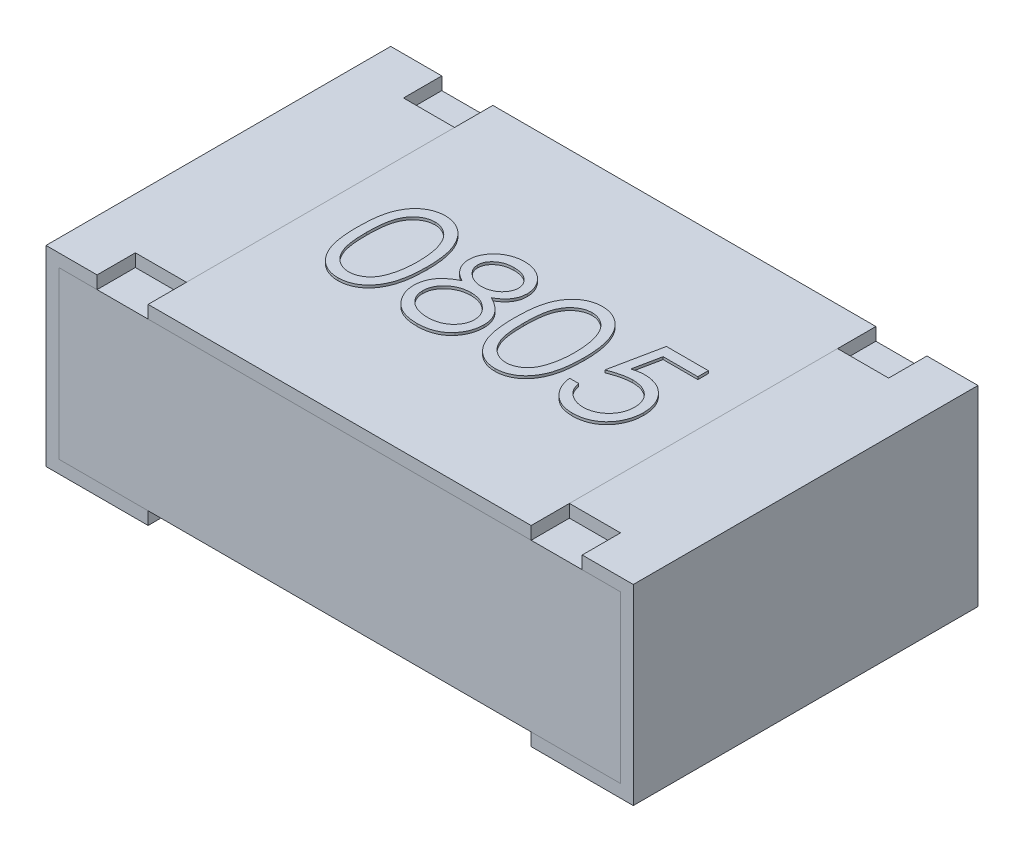
from build123d import *

# Parameters (mm, degrees)
CROQUIS1_W          = 2.2
CROQUIS1_H          = 1.35
EXTRUIR1_DEPTH      = 0.7
CROQUIS2_W          = 2.2
CROQUIS2_H          = 0.05
EXTRUIR2_DEPTH      = 2.876832438
CROQUIS4_W          = 1.35
CROQUIS4_H          = 0.05
EXTRUIR3_DEPTH      = 1.5
CROQUIS5_W          = 0.2
CROQUIS5_H          = 0.15
EXTRUIR4_DEPTH      = 0.05
BOSS_EXTRUDE1_DEPTH = 0.01


with BuildPart() as part:
    # Croquis1 → Extruir1 (new body)
    with BuildSketch(Plane(origin=(0, 0, 0), x_dir=(1, 0, 0), z_dir=(0, 1, 0))):
        Rectangle(CROQUIS1_W, CROQUIS1_H)
    extrude(amount=EXTRUIR1_DEPTH)

    # Croquis2 → Extruir2 (cut, through all)
    with BuildSketch(Plane.XY.offset(0.675)):
        with Locations((0, 0.025)):
            Rectangle(CROQUIS2_W, CROQUIS2_H)
    extrude(amount=-EXTRUIR2_DEPTH, mode=Mode.SUBTRACT)


with BuildPart() as body_2:
    # Barrer1: sweep along a path in Croquis3
    with BuildLine(Plane.XY.offset(0.675)) as barrer1_path:
        Line((-0.75, 0.75), (-1.15, 0.75))
        Line((-1.15, 0.75), (-1.15, 0))
        Line((-1.15, 0), (-0.75, 0))
    # Croquis3D1 → Barrer1 (sweep)
    with BuildSketch(Plane(origin=(-0.75, 0.75, 0.675), x_dir=(0, -0.0370116605098802, -0.9993148337667672), z_dir=(-1, 0, 0))):
        Polygon((0, 0), (1.349075026, -0.049965742), (1.350925609, 0), (0.001850583, 0.049965742), align=None)
    sweep(path=barrer1_path.line, transition=Transition.RIGHT)


with BuildPart() as body_3:
    # Simetría1: mirrored copy
    add(body_2.part.mirror(Plane(origin=(0, 0.7, 0.675), x_dir=(0, 0, 1), z_dir=(1, 0, 0))))


with BuildPart() as body_4:
    # Croquis4 → Extruir3 (new body)
    with BuildSketch(Plane(origin=(-0.75, 0, 0), x_dir=(0, 0, -1), z_dir=(1, 0, 0))):
        with Locations((0, 0.725)):
            Rectangle(CROQUIS4_W, CROQUIS4_H)
    extrude(amount=EXTRUIR3_DEPTH)

    # Sketch1 → Boss-Extrude1 (add)
    with BuildSketch(Plane(origin=(0, 0.75, 0), x_dir=(1, 0, 0), z_dir=(0, 1, 0))):
        with BuildLine():
            add(Edge.make_bspline(
                [(-0.59261561, -0.012986983), (-0.592578122, -0.006575853), (-0.592505301, 0.005877859), (-0.591695196, 0.024024675), (-0.590349443, 0.041048708), (-0.588505172, 0.056950773), (-0.586260831, 0.071734975), (-0.583264775, 0.085361804), (-0.579857598, 0.097894331), (-0.575908747, 0.109373422), (-0.571453, 0.119953731), (-0.56660337, 0.129830897), (-0.561167393, 0.138989975), (-0.555455746, 0.147577151), (-0.549237224, 0.155451859), (-0.542688791, 0.162725306), (-0.535554862, 0.169229392), (-0.528077947, 0.175154683), (-0.520190351, 0.180348909), (-0.512116903, 0.184924079), (-0.503802034, 0.188832635), (-0.495223042, 0.191905828), (-0.486457035, 0.19444421), (-0.47747337, 0.19618009), (-0.468257214, 0.197272308), (-0.462036479, 0.197376727), (-0.458881635, 0.197429683)],
                knots=[0, 0, 0, 0, 1.646270934, 3.197905019, 4.663502075, 6.030701355, 7.308322542, 8.50163776, 9.611534131, 10.641858119, 11.616356847, 12.558055219, 13.465016945, 14.349605745, 15.204443733, 16.039544428, 16.859896111, 17.680448484, 18.487036065, 19.28249412, 20.06191084, 20.843045899, 21.620316918, 22.403196591, 23.190181807, 24, 24, 24, 24], degree=3))
            add(Edge.make_bspline(
                [(-0.458881635, 0.197429683), (-0.455700438, 0.197373933), (-0.449374037, 0.197263063), (-0.440020851, 0.19619747), (-0.430883745, 0.194429341), (-0.422001672, 0.191924087), (-0.413301673, 0.18881601), (-0.404851798, 0.184920339), (-0.39659956, 0.180385612), (-0.388676099, 0.175057168), (-0.380994428, 0.169116337), (-0.373743233, 0.162400603), (-0.366921851, 0.154977778), (-0.360444674, 0.146927279), (-0.354495463, 0.138094698), (-0.348829927, 0.128633657), (-0.343758838, 0.118378701), (-0.338874875, 0.107500934), (-0.334659219, 0.095699372), (-0.330857363, 0.083040543), (-0.32778548, 0.069374921), (-0.325226706, 0.054774208), (-0.323244433, 0.039184781), (-0.321800702, 0.022640059), (-0.321038064, 0.005129157), (-0.320894441, -0.006843168), (-0.320820738, -0.012986983)],
                knots=[0, 0, 0, 0, 0.810914788, 1.612654377, 2.396697861, 3.181598691, 3.963628158, 4.749916497, 5.551656086, 6.361998678, 7.18212741, 8.025565596, 8.878627764, 9.750805457, 10.657531673, 11.591944965, 12.560506719, 13.57287815, 14.630710178, 15.753379473, 16.941251878, 18.199788006, 19.531962791, 20.947069417, 22.433333509, 24, 24, 24, 24], degree=3))
            add(Edge.make_bspline(
                [(-0.320820738, -0.012986983), (-0.320895205, -0.019104001), (-0.3210403, -0.031022762), (-0.321792153, -0.048454873), (-0.323273139, -0.064911792), (-0.325125709, -0.080432988), (-0.327691533, -0.094953859), (-0.33084641, -0.108524653), (-0.334349304, -0.121203975), (-0.33867328, -0.132887954), (-0.343405933, -0.143739579), (-0.348555098, -0.153872968), (-0.35407165, -0.163377687), (-0.360081792, -0.172177658), (-0.366487896, -0.180335219), (-0.373427072, -0.187706376), (-0.38070371, -0.194468738), (-0.388407986, -0.200486067), (-0.396455021, -0.205752902), (-0.404678915, -0.210463056), (-0.413225588, -0.214261078), (-0.421901354, -0.217522226), (-0.43083031, -0.220013706), (-0.440001326, -0.221736433), (-0.449367753, -0.222944644), (-0.45569936, -0.223036813), (-0.458881635, -0.223083137)],
                knots=[0, 0, 0, 0, 1.561518951, 3.042555995, 4.452378317, 5.7783523, 7.031515105, 8.214008947, 9.334062868, 10.386615937, 11.391082383, 12.354592575, 13.286541444, 14.194233754, 15.072674879, 15.931287219, 16.775624067, 17.606195743, 18.42308326, 19.229000347, 20.022332153, 20.807536673, 21.593273796, 22.3848459, 23.188221202, 24, 24, 24, 24], degree=3))
            add(Edge.make_bspline(
                [(-0.458881635, -0.223083137), (-0.462036391, -0.22302984), (-0.468256954, -0.222924747), (-0.477474374, -0.221837463), (-0.486420939, -0.220089406), (-0.495140797, -0.217641794), (-0.503678684, -0.214645812), (-0.51191826, -0.210742534), (-0.519951138, -0.206247212), (-0.527755887, -0.201127735), (-0.535185849, -0.1952624), (-0.542282832, -0.188775053), (-0.548868548, -0.181503806), (-0.554998159, -0.173563472), (-0.560823769, -0.165027101), (-0.566182555, -0.155778144), (-0.571139224, -0.145853275), (-0.575669909, -0.135188371), (-0.579686899, -0.123627807), (-0.583235208, -0.11103933), (-0.586036826, -0.097311829), (-0.588434878, -0.082555558), (-0.590369094, -0.066707109), (-0.591689588, -0.049757877), (-0.592505738, -0.031718425), (-0.592578318, -0.019344736), (-0.59261561, -0.012986983)],
                knots=[0, 0, 0, 0, 0.810891512, 1.598919785, 2.382837074, 3.152667961, 3.926044502, 4.706494248, 5.493654104, 6.291793342, 7.103789334, 7.925228297, 8.761435821, 9.622817696, 10.50288917, 11.416980706, 12.369136599, 13.353924996, 14.394355917, 15.514179734, 16.714354668, 17.994756427, 19.357759367, 20.818452758, 22.365282078, 24, 24, 24, 24], degree=3))
        make_face()
        with BuildLine():
            add(Edge.make_bspline(
                [(-0.556718174, -0.012826727), (-0.556704523, -0.018169435), (-0.556678029, -0.028538583), (-0.555985892, -0.043606385), (-0.555043008, -0.057660137), (-0.55382686, -0.070717684), (-0.552020808, -0.082734828), (-0.549997175, -0.09379422), (-0.547534537, -0.103837333), (-0.54462082, -0.112933083), (-0.541302066, -0.121235834), (-0.537678539, -0.128961687), (-0.533785885, -0.136201908), (-0.529429411, -0.142891463), (-0.524684832, -0.149052168), (-0.519659317, -0.154793063), (-0.514165307, -0.159912718), (-0.506564879, -0.16605293), (-0.496530997, -0.172397974), (-0.483888659, -0.177923241), (-0.470897979, -0.181395522), (-0.462080693, -0.181837094), (-0.457679712, -0.182057496)],
                knots=[0, 0, 0, 0, 1.459021318, 2.831673884, 4.118529203, 5.306027144, 6.411944654, 7.436330062, 8.375795394, 9.233974572, 10.042671642, 10.816086306, 11.563610507, 12.285937304, 12.993564865, 13.685989202, 14.367179055, 15.041617293, 16.353048772, 17.594441528, 18.799311195, 20, 20, 20, 20], degree=3))
            add(Edge.make_bspline(
                [(-0.457679712, -0.182057496), (-0.453250264, -0.181874893), (-0.444400513, -0.181510063), (-0.431470936, -0.177990207), (-0.418918906, -0.172679402), (-0.409082112, -0.166399688), (-0.401598393, -0.160419307), (-0.396236451, -0.15532049), (-0.391315074, -0.149611248), (-0.386647409, -0.143451329), (-0.382366371, -0.136723045), (-0.378473441, -0.12945875), (-0.374921059, -0.121638273), (-0.372897168, -0.116178874), (-0.371862405, -0.113387624)],
                knots=[0, 0, 0, 0, 1.353760809, 2.704726607, 4.075137775, 5.516104923, 6.260822281, 7.007110065, 7.778089737, 8.566572457, 9.372053459, 10.217411131, 11.088608312, 12, 12, 12, 12], degree=3))
            add(Edge.make_bspline(
                [(-0.371862405, -0.113387624), (-0.370656488, -0.109818511), (-0.368207961, -0.102571681), (-0.36505233, -0.091330121), (-0.362567141, -0.079535519), (-0.360331328, -0.067258363), (-0.358805265, -0.054408112), (-0.357576943, -0.041024525), (-0.356853436, -0.027097512), (-0.35676375, -0.017635227), (-0.356718174, -0.012826727)],
                knots=[0, 0, 0, 0, 0.884706709, 1.796334032, 2.740027952, 3.714592787, 4.726048262, 5.777819803, 6.87074269, 8, 8, 8, 8], degree=3))
            add(Edge.make_bspline(
                [(-0.356718174, -0.012826727), (-0.356781053, -0.008019004), (-0.356904057, 0.001385929), (-0.357374227, 0.015159435), (-0.35858835, 0.028241465), (-0.359936821, 0.040688376), (-0.361925074, 0.052431268), (-0.364068824, 0.063568445), (-0.366948962, 0.073961934), (-0.370025508, 0.083774458), (-0.373546696, 0.092894532), (-0.37742278, 0.101364679), (-0.38156241, 0.109225791), (-0.386058666, 0.116456298), (-0.390858172, 0.123088589), (-0.396087606, 0.128989686), (-0.401539535, 0.134342482), (-0.409175785, 0.14045249), (-0.419172846, 0.146682398), (-0.431612349, 0.152415628), (-0.444557565, 0.155708004), (-0.453308817, 0.156172197), (-0.457679712, 0.156404042)],
                knots=[0, 0, 0, 0, 1.31362396, 2.569729283, 3.763502607, 4.902122613, 5.988968491, 7.01645872, 7.998833611, 8.933434873, 9.825090667, 10.667526885, 11.477055099, 12.250526234, 12.991942729, 13.710640831, 14.402115721, 15.076753259, 16.378508321, 17.609869233, 18.806226677, 20, 20, 20, 20], degree=3))
            add(Edge.make_bspline(
                [(-0.457679712, 0.156404042), (-0.46210378, 0.156171877), (-0.470959975, 0.155707123), (-0.484039741, 0.152427894), (-0.496577381, 0.146712127), (-0.506548007, 0.140431856), (-0.514189583, 0.134450334), (-0.519570462, 0.129263311), (-0.524615739, 0.123589453), (-0.529263476, 0.117372092), (-0.533616537, 0.110690335), (-0.537614367, 0.103491619), (-0.541216347, 0.095739463), (-0.544540294, 0.087440442), (-0.547462899, 0.078345477), (-0.549873637, 0.068314735), (-0.552100729, 0.057290519), (-0.553677331, 0.045208289), (-0.555078903, 0.032147472), (-0.555979629, 0.018058636), (-0.556680344, 0.002965563), (-0.556705311, -0.007457197), (-0.556718174, -0.012826727)],
                knots=[0, 0, 0, 0, 1.207732386, 2.417664972, 3.655092373, 4.956220595, 5.625982001, 6.301752483, 6.994047911, 7.697131622, 8.419323945, 9.170223765, 9.943494443, 10.752040957, 11.610060368, 12.549350801, 13.567764191, 14.679664412, 15.874934091, 17.154273443, 18.533957287, 20, 20, 20, 20], degree=3))
        make_face(mode=Mode.SUBTRACT)
        with BuildLine():
            add(Edge.make_bspline(
                [(-0.090452148, 0.010009811), (-0.087178029, 0.008302616), (-0.080792402, 0.004973016), (-0.071697864, -0.000388221), (-0.063386435, -0.006038617), (-0.055627514, -0.011711287), (-0.048557416, -0.017623476), (-0.042255198, -0.023798694), (-0.036565184, -0.030082802), (-0.031602123, -0.036582212), (-0.02723677, -0.043279657), (-0.023463955, -0.050192717), (-0.020239132, -0.057306241), (-0.017683367, -0.064697879), (-0.01557802, -0.072259052), (-0.014129379, -0.080087392), (-0.013350303, -0.088131317), (-0.01320301, -0.093567694), (-0.01312843, -0.096320317)],
                knots=[0, 0, 0, 0, 1.272397273, 2.481599622, 3.635517121, 4.734568067, 5.792894095, 6.808321871, 7.773003508, 8.711915296, 9.623354172, 10.525449501, 11.423591555, 12.311487226, 13.218079475, 14.126165749, 15.051214107, 16, 16, 16, 16], degree=3))
            add(Edge.make_bspline(
                [(-0.01312843, -0.096320317), (-0.013216593, -0.100171486), (-0.013391099, -0.107794396), (-0.014911097, -0.11904538), (-0.017186866, -0.129972441), (-0.020510239, -0.140573182), (-0.024820341, -0.150789111), (-0.030131979, -0.160628971), (-0.036144688, -0.170254034), (-0.040973516, -0.176176252), (-0.043416892, -0.179172881)],
                knots=[0, 0, 0, 0, 1.025265484, 2.029385089, 3.018602448, 3.995076438, 4.983346944, 5.966715145, 6.97116228, 8, 8, 8, 8], degree=3))
            add(Edge.make_bspline(
                [(-0.043416892, -0.179172881), (-0.046598203, -0.182669312), (-0.052921514, -0.189618969), (-0.063753848, -0.198641918), (-0.075642063, -0.206224706), (-0.088540159, -0.212404351), (-0.102413656, -0.217214164), (-0.117259599, -0.220670451), (-0.133106931, -0.222650158), (-0.143998985, -0.222936328), (-0.149586764, -0.223083137)],
                knots=[0, 0, 0, 0, 0.954267603, 1.896743057, 2.838368354, 3.796610408, 4.779680527, 5.799409237, 6.871065594, 8, 8, 8, 8], degree=3))
            add(Edge.make_bspline(
                [(-0.149586764, -0.223083137), (-0.154959722, -0.222951426), (-0.165414954, -0.222695128), (-0.180632997, -0.220958621), (-0.194818491, -0.217915437), (-0.208053916, -0.213750338), (-0.220259481, -0.208332027), (-0.231400407, -0.201588208), (-0.241637432, -0.193790329), (-0.250659886, -0.184714435), (-0.258669994, -0.174993535), (-0.265706343, -0.16496478), (-0.271554809, -0.154627253), (-0.276506477, -0.144135097), (-0.280297108, -0.133341251), (-0.282922504, -0.122301249), (-0.284589854, -0.111034376), (-0.284811698, -0.103430758), (-0.284923302, -0.099605573)],
                knots=[0, 0, 0, 0, 1.256902934, 2.445805442, 3.576955095, 4.645999104, 5.686449165, 6.692658513, 7.68621702, 8.689161843, 9.678783111, 10.630372946, 11.551080876, 12.453998257, 13.34127905, 14.221779781, 15.105423033, 16, 16, 16, 16], degree=3))
            add(Edge.make_bspline(
                [(-0.284923302, -0.099605573), (-0.284857259, -0.096798808), (-0.284726733, -0.09125165), (-0.283823322, -0.083056299), (-0.282370926, -0.075079598), (-0.280398417, -0.067292084), (-0.277725157, -0.059750453), (-0.274497485, -0.05241897), (-0.270733833, -0.045289359), (-0.2663817, -0.03832263), (-0.261318611, -0.0316164), (-0.255585623, -0.025056857), (-0.249068152, -0.018745787), (-0.241838705, -0.012606081), (-0.233979901, -0.006528827), (-0.225287612, -0.000842458), (-0.215992267, 0.004855595), (-0.209385935, 0.008262261), (-0.20599702, 0.010009811)],
                knots=[0, 0, 0, 0, 0.941657376, 1.861047343, 2.762797495, 3.66048619, 4.553285746, 5.444104102, 6.34607688, 7.256116206, 8.197091036, 9.162375105, 10.176350973, 11.237807142, 12.343728897, 13.50695164, 14.721116704, 16, 16, 16, 16], degree=3))
            add(Edge.make_bspline(
                [(-0.20599702, 0.010009811), (-0.210636034, 0.012539499), (-0.219618464, 0.017437683), (-0.231512115, 0.026437318), (-0.241728186, 0.036184497), (-0.249985868, 0.046885045), (-0.256485551, 0.058204688), (-0.26094482, 0.070072602), (-0.263961561, 0.082268729), (-0.264260399, 0.090600866), (-0.264410482, 0.094785452)],
                knots=[0, 0, 0, 0, 1.166880483, 2.259407225, 3.286803203, 4.280235371, 5.237608625, 6.161067461, 7.076446754, 8, 8, 8, 8], degree=3))
            add(Edge.make_bspline(
                [(-0.264410482, 0.094785452), (-0.264223576, 0.099048031), (-0.263847863, 0.107616556), (-0.260809769, 0.120371541), (-0.255858905, 0.132899149), (-0.249125076, 0.145138659), (-0.240737966, 0.156675826), (-0.230675504, 0.167023363), (-0.219177984, 0.176087532), (-0.206302799, 0.183696238), (-0.192447229, 0.189888656), (-0.177828289, 0.194160476), (-0.16270069, 0.196953175), (-0.152403808, 0.197269364), (-0.147182918, 0.197429683)],
                knots=[0, 0, 0, 0, 0.888701115, 1.786444228, 2.72001202, 3.692817113, 4.693886446, 5.687152267, 6.695133018, 7.739871481, 8.800368666, 9.853104506, 10.91144658, 12, 12, 12, 12], degree=3))
            add(Edge.make_bspline(
                [(-0.147182918, 0.197429683), (-0.142096767, 0.197264387), (-0.132067458, 0.196938441), (-0.117325215, 0.194219941), (-0.103219515, 0.189679424), (-0.089799001, 0.183519742), (-0.07730393, 0.175932663), (-0.066263666, 0.166743991), (-0.056511371, 0.1564421), (-0.048444583, 0.144908431), (-0.041797396, 0.132715952), (-0.037168721, 0.119959092), (-0.034202782, 0.106913485), (-0.033828683, 0.098086285), (-0.033641251, 0.093663658)],
                knots=[0, 0, 0, 0, 1.072916533, 2.115669174, 3.151510826, 4.193348718, 5.225979165, 6.227137561, 7.216255879, 8.211077061, 9.189680878, 10.138522389, 11.067357538, 12, 12, 12, 12], degree=3))
            add(Edge.make_bspline(
                [(-0.033641251, 0.093663658), (-0.033805201, 0.089323467), (-0.034127189, 0.080799581), (-0.036835753, 0.068373693), (-0.041397275, 0.056736888), (-0.047625179, 0.045757122), (-0.055742378, 0.035633522), (-0.065640519, 0.026237354), (-0.077240688, 0.017491431), (-0.085956217, 0.012555847), (-0.090452148, 0.010009811)],
                knots=[0, 0, 0, 0, 0.975232327, 1.915300861, 2.843280834, 3.77672583, 4.742871857, 5.749627742, 6.839139064, 8, 8, 8, 8], degree=3))
        make_face()
        with BuildLine():
            add(Edge.make_bspline(
                [(-0.149186123, 0.156404042), (-0.151991929, 0.156329592), (-0.157481313, 0.156183934), (-0.165530304, 0.155422947), (-0.173184289, 0.15394258), (-0.180523238, 0.151972441), (-0.18744653, 0.149310957), (-0.194048194, 0.146180099), (-0.200215873, 0.142373691), (-0.206024022, 0.13810384), (-0.211252682, 0.133407508), (-0.215893202, 0.128514511), (-0.219747843, 0.123328752), (-0.223021113, 0.117979226), (-0.225396144, 0.11230716), (-0.227174921, 0.106486454), (-0.228377366, 0.100443553), (-0.228467468, 0.096313666), (-0.228513046, 0.094224555)],
                knots=[0, 0, 0, 0, 1.203892937, 2.355340988, 3.463153438, 4.544400666, 5.610487187, 6.640501085, 7.674077295, 8.714426146, 9.728707835, 10.68524104, 11.601827946, 12.495867327, 13.368432065, 14.231010473, 15.105153427, 16, 16, 16, 16], degree=3))
            add(Edge.make_bspline(
                [(-0.228513046, 0.094224555), (-0.22843449, 0.092135354), (-0.228279251, 0.088006792), (-0.227078665, 0.081910122), (-0.22528931, 0.075919078), (-0.222472092, 0.070176117), (-0.219093079, 0.064482018), (-0.214922625, 0.058979094), (-0.20995245, 0.053648193), (-0.204349314, 0.048534657), (-0.198245139, 0.043746227), (-0.191778391, 0.039589292), (-0.185030232, 0.036111108), (-0.178069995, 0.033216319), (-0.170826744, 0.03096604), (-0.163344862, 0.029369623), (-0.15562309, 0.028377395), (-0.150391023, 0.028258879), (-0.147743815, 0.028198914)],
                knots=[0, 0, 0, 0, 0.873023192, 1.725219244, 2.590779336, 3.480155217, 4.391973325, 5.357036234, 6.360879153, 7.436073238, 8.526419356, 9.601555421, 10.645666583, 11.697338044, 12.750135903, 13.812665442, 14.89329948, 16, 16, 16, 16], degree=3))
            add(Edge.make_bspline(
                [(-0.147743815, 0.028198914), (-0.144343803, 0.02829867), (-0.137577361, 0.028497197), (-0.12760258, 0.030343046), (-0.117903992, 0.033246579), (-0.10858526, 0.037219147), (-0.099887594, 0.042205188), (-0.092134443, 0.048174676), (-0.085391941, 0.054989773), (-0.079730157, 0.062544382), (-0.07534046, 0.070584564), (-0.071923111, 0.078653169), (-0.069927543, 0.086836281), (-0.06966725, 0.09231822), (-0.069538687, 0.095025837)],
                knots=[0, 0, 0, 0, 1.076279235, 2.141928126, 3.20205304, 4.278698113, 5.344010996, 6.36967002, 7.368914609, 8.37248503, 9.349703398, 10.264243087, 11.142681841, 12, 12, 12, 12], degree=3))
            add(Edge.make_bspline(
                [(-0.069538687, 0.095025837), (-0.069599475, 0.096926184), (-0.069720131, 0.1006981), (-0.070714423, 0.106268199), (-0.072357376, 0.11171158), (-0.074581728, 0.117073211), (-0.077508561, 0.122277866), (-0.080978754, 0.127407362), (-0.085194126, 0.132346306), (-0.089925147, 0.137209798), (-0.095290336, 0.141710829), (-0.101279355, 0.145669082), (-0.107861498, 0.149030494), (-0.115036921, 0.151760637), (-0.122779198, 0.153811191), (-0.131052669, 0.155346774), (-0.13992632, 0.156212273), (-0.146032577, 0.156338733), (-0.149186123, 0.156404042)],
                knots=[0, 0, 0, 0, 0.814439003, 1.616544685, 2.417341072, 3.248991801, 4.09997495, 4.973547432, 5.9003056, 6.880240646, 7.880314356, 8.896779544, 9.951930927, 11.043077905, 12.18215768, 13.381699519, 14.647792085, 16, 16, 16, 16], degree=3))
        make_face(mode=Mode.SUBTRACT)
        with BuildLine():
            add(Edge.make_bspline(
                [(-0.146862405, -0.012826727), (-0.150419637, -0.01289), (-0.15739806, -0.013014127), (-0.167621709, -0.014395784), (-0.177433499, -0.016319143), (-0.186800349, -0.019236954), (-0.195718303, -0.023030838), (-0.204235638, -0.027594786), (-0.212287196, -0.032989693), (-0.219761793, -0.039147021), (-0.226587316, -0.045782387), (-0.232575693, -0.052806631), (-0.237661124, -0.060089206), (-0.241756353, -0.067722604), (-0.245117694, -0.075545188), (-0.247324994, -0.08375177), (-0.248740047, -0.092184583), (-0.248930062, -0.097917166), (-0.249025866, -0.100807496)],
                knots=[0, 0, 0, 0, 1.140299081, 2.23698856, 3.303958914, 4.344563908, 5.37730929, 6.408454204, 7.439741482, 8.480804886, 9.510774543, 10.48932336, 11.43758569, 12.353841022, 13.263987381, 14.161954604, 15.073269652, 16, 16, 16, 16], degree=3))
            add(Edge.make_bspline(
                [(-0.249025866, -0.100807496), (-0.248870065, -0.1043996), (-0.24856096, -0.111526249), (-0.246108772, -0.122059172), (-0.242173283, -0.132255864), (-0.236684687, -0.14203323), (-0.229888393, -0.151170385), (-0.221531082, -0.159134816), (-0.212132129, -0.166211557), (-0.201373517, -0.171935046), (-0.189621692, -0.176505887), (-0.176879781, -0.17965514), (-0.163330647, -0.181739877), (-0.153975265, -0.181949955), (-0.149186123, -0.182057496)],
                knots=[0, 0, 0, 0, 0.898778495, 1.783155532, 2.693654817, 3.627872908, 4.583023416, 5.533784346, 6.509005473, 7.520592997, 8.575161974, 9.658835044, 10.801527049, 12, 12, 12, 12], degree=3))
            add(Edge.make_bspline(
                [(-0.149186123, -0.182057496), (-0.145443223, -0.181985632), (-0.138150856, -0.181845619), (-0.127512461, -0.180609699), (-0.117473084, -0.178649742), (-0.108052193, -0.175799051), (-0.099144326, -0.172319054), (-0.090900514, -0.167842245), (-0.083108682, -0.162750551), (-0.076152782, -0.156709618), (-0.069817559, -0.150254819), (-0.064293754, -0.143421671), (-0.059498605, -0.136395885), (-0.055735067, -0.129018686), (-0.052726353, -0.12143161), (-0.050563661, -0.113564695), (-0.049229236, -0.105393811), (-0.049094276, -0.09985106), (-0.049025866, -0.097041471)],
                knots=[0, 0, 0, 0, 1.224942928, 2.386581632, 3.501229538, 4.569074225, 5.605009692, 6.626002462, 7.634866581, 8.645888296, 9.63523824, 10.59253846, 11.518950513, 12.414518923, 13.29783783, 14.186679152, 15.080837789, 16, 16, 16, 16], degree=3))
            add(Edge.make_bspline(
                [(-0.049025866, -0.097041471), (-0.049129392, -0.094312632), (-0.049333526, -0.088931838), (-0.050629148, -0.080958521), (-0.052905248, -0.073255342), (-0.056028379, -0.065729627), (-0.060186204, -0.058533861), (-0.06508276, -0.051480584), (-0.070990659, -0.044765562), (-0.077666385, -0.038336637), (-0.084941694, -0.032391981), (-0.092675082, -0.027133188), (-0.100807021, -0.022704375), (-0.109320302, -0.01910249), (-0.118196023, -0.016269636), (-0.127427655, -0.014290665), (-0.137026006, -0.013044996), (-0.143546563, -0.012900305), (-0.146862405, -0.012826727)],
                knots=[0, 0, 0, 0, 0.917430815, 1.809013306, 2.70690318, 3.612392954, 4.541220862, 5.495268465, 6.494511384, 7.542276156, 8.608045339, 9.649016899, 10.681629292, 11.715607085, 12.752076957, 13.808767841, 14.885711793, 16, 16, 16, 16], degree=3))
        make_face(mode=Mode.SUBTRACT)
        with BuildLine():
            add(Edge.make_bspline(
                [(0.022769006, -0.012986983), (0.022806493, -0.006575853), (0.022879314, 0.005877859), (0.023689419, 0.024024675), (0.025035173, 0.041048708), (0.026879444, 0.056950773), (0.029123784, 0.071734975), (0.03211984, 0.085361804), (0.035527017, 0.097894331), (0.039475868, 0.109373422), (0.043931616, 0.119953731), (0.048781245, 0.129830897), (0.054217222, 0.138989975), (0.059928869, 0.147577151), (0.066147392, 0.155451859), (0.072695825, 0.162725306), (0.079829754, 0.169229392), (0.087306669, 0.175154683), (0.095194265, 0.180348909), (0.103267712, 0.184924079), (0.111582582, 0.188832635), (0.120161574, 0.191905828), (0.12892758, 0.19444421), (0.137911245, 0.19618009), (0.147127401, 0.197272308), (0.153348137, 0.197376727), (0.15650298, 0.197429683)],
                knots=[0, 0, 0, 0, 1.646270934, 3.197905019, 4.663502075, 6.030701355, 7.308322542, 8.50163776, 9.611534131, 10.641858119, 11.616356847, 12.558055219, 13.465016945, 14.349605745, 15.204443733, 16.039544428, 16.859896111, 17.680448484, 18.487036065, 19.28249412, 20.06191084, 20.843045899, 21.620316918, 22.403196591, 23.190181807, 24, 24, 24, 24], degree=3))
            add(Edge.make_bspline(
                [(0.15650298, 0.197429683), (0.159684177, 0.197373933), (0.166010578, 0.197263063), (0.175363764, 0.19619747), (0.184500871, 0.194429341), (0.193382944, 0.191924087), (0.202082942, 0.18881601), (0.210532817, 0.184920339), (0.218785055, 0.180385612), (0.226708517, 0.175057168), (0.234390187, 0.169116337), (0.241641383, 0.162400603), (0.248462764, 0.154977778), (0.254939942, 0.146927279), (0.260889153, 0.138094698), (0.266554688, 0.128633657), (0.271625778, 0.118378701), (0.276509741, 0.107500934), (0.280725396, 0.095699372), (0.284527253, 0.083040543), (0.287599135, 0.069374921), (0.290157909, 0.054774208), (0.292140183, 0.039184781), (0.293583913, 0.022640059), (0.294346552, 0.005129157), (0.294490175, -0.006843168), (0.294563877, -0.012986983)],
                knots=[0, 0, 0, 0, 0.810914788, 1.612654377, 2.396697861, 3.181598691, 3.963628158, 4.749916497, 5.551656086, 6.361998678, 7.18212741, 8.025565596, 8.878627764, 9.750805457, 10.657531673, 11.591944965, 12.560506719, 13.57287815, 14.630710178, 15.753379473, 16.941251878, 18.199788006, 19.531962791, 20.947069417, 22.433333509, 24, 24, 24, 24], degree=3))
            add(Edge.make_bspline(
                [(0.294563877, -0.012986983), (0.294489411, -0.019104001), (0.294344315, -0.031022762), (0.293592463, -0.048454873), (0.292111476, -0.064911792), (0.290258906, -0.080432988), (0.287693082, -0.094953859), (0.284538206, -0.108524653), (0.281035312, -0.121203975), (0.276711335, -0.132887954), (0.271978683, -0.143739579), (0.266829517, -0.153872968), (0.261312966, -0.163377687), (0.255302824, -0.172177658), (0.248896719, -0.180335219), (0.241957543, -0.187706376), (0.234680905, -0.194468738), (0.226976629, -0.200486067), (0.218929595, -0.205752902), (0.2107057, -0.210463056), (0.202159028, -0.214261078), (0.193483262, -0.217522226), (0.184554305, -0.220013706), (0.175383289, -0.221736433), (0.166016862, -0.222944644), (0.159685255, -0.223036813), (0.15650298, -0.223083137)],
                knots=[0, 0, 0, 0, 1.561518951, 3.042555995, 4.452378317, 5.7783523, 7.031515105, 8.214008947, 9.334062868, 10.386615937, 11.391082383, 12.354592575, 13.286541444, 14.194233754, 15.072674879, 15.931287219, 16.775624067, 17.606195743, 18.42308326, 19.229000347, 20.022332153, 20.807536673, 21.593273796, 22.3848459, 23.188221202, 24, 24, 24, 24], degree=3))
            add(Edge.make_bspline(
                [(0.15650298, -0.223083137), (0.153348224, -0.22302984), (0.147127661, -0.222924747), (0.137910241, -0.221837463), (0.128963676, -0.220089406), (0.120243819, -0.217641794), (0.111705931, -0.214645812), (0.103466356, -0.210742534), (0.095433477, -0.206247212), (0.087628728, -0.201127735), (0.080198767, -0.1952624), (0.073101783, -0.188775053), (0.066516067, -0.181503806), (0.060386456, -0.173563472), (0.054560846, -0.165027101), (0.04920206, -0.155778144), (0.044245391, -0.145853275), (0.039714707, -0.135188371), (0.035697717, -0.123627807), (0.032149407, -0.11103933), (0.029347789, -0.097311829), (0.026949737, -0.082555558), (0.025015522, -0.066707109), (0.023695028, -0.049757877), (0.022878877, -0.031718425), (0.022806298, -0.019344736), (0.022769006, -0.012986983)],
                knots=[0, 0, 0, 0, 0.810891512, 1.598919785, 2.382837074, 3.152667961, 3.926044502, 4.706494248, 5.493654104, 6.291793342, 7.103789334, 7.925228297, 8.761435821, 9.622817696, 10.50288917, 11.416980706, 12.369136599, 13.353924996, 14.394355917, 15.514179734, 16.714354668, 17.994756427, 19.357759367, 20.818452758, 22.365282078, 24, 24, 24, 24], degree=3))
        make_face()
        with BuildLine():
            add(Edge.make_bspline(
                [(0.058666441, -0.012826727), (0.058680093, -0.018169435), (0.058706587, -0.028538583), (0.059398724, -0.043606385), (0.060341608, -0.057660137), (0.061557756, -0.070717684), (0.063363807, -0.082734828), (0.06538744, -0.09379422), (0.067850079, -0.103837333), (0.070763795, -0.112933083), (0.074082549, -0.121235834), (0.077706076, -0.128961687), (0.08159873, -0.136201908), (0.085955205, -0.142891463), (0.090699783, -0.149052168), (0.095725299, -0.154793063), (0.101219308, -0.159912718), (0.108819736, -0.16605293), (0.118853619, -0.172397974), (0.131495957, -0.177923241), (0.144486637, -0.181395522), (0.153303922, -0.181837094), (0.157704903, -0.182057496)],
                knots=[0, 0, 0, 0, 1.459021318, 2.831673884, 4.118529203, 5.306027144, 6.411944654, 7.436330062, 8.375795394, 9.233974572, 10.042671642, 10.816086306, 11.563610507, 12.285937304, 12.993564865, 13.685989202, 14.367179055, 15.041617293, 16.353048772, 17.594441528, 18.799311195, 20, 20, 20, 20], degree=3))
            add(Edge.make_bspline(
                [(0.157704903, -0.182057496), (0.162134351, -0.181874893), (0.170984102, -0.181510063), (0.183913679, -0.177990207), (0.19646571, -0.172679402), (0.206302503, -0.166399688), (0.213786222, -0.160419307), (0.219148164, -0.15532049), (0.224069541, -0.149611248), (0.228737207, -0.143451329), (0.233018244, -0.136723045), (0.236911174, -0.12945875), (0.240463556, -0.121638273), (0.242487447, -0.116178874), (0.243522211, -0.113387624)],
                knots=[0, 0, 0, 0, 1.353760809, 2.704726607, 4.075137775, 5.516104923, 6.260822281, 7.007110065, 7.778089737, 8.566572457, 9.372053459, 10.217411131, 11.088608312, 12, 12, 12, 12], degree=3))
            add(Edge.make_bspline(
                [(0.243522211, -0.113387624), (0.244728127, -0.109818511), (0.247176654, -0.102571681), (0.250332286, -0.091330121), (0.252817474, -0.079535519), (0.255053287, -0.067258363), (0.256579351, -0.054408112), (0.257807672, -0.041024525), (0.258531179, -0.027097512), (0.258620865, -0.017635227), (0.258666441, -0.012826727)],
                knots=[0, 0, 0, 0, 0.884706709, 1.796334032, 2.740027952, 3.714592787, 4.726048262, 5.777819803, 6.87074269, 8, 8, 8, 8], degree=3))
            add(Edge.make_bspline(
                [(0.258666441, -0.012826727), (0.258603563, -0.008019004), (0.258480558, 0.001385929), (0.258010388, 0.015159435), (0.256796266, 0.028241465), (0.255447795, 0.040688376), (0.253459541, 0.052431268), (0.251315792, 0.063568445), (0.248435653, 0.073961934), (0.245359107, 0.083774458), (0.241837919, 0.092894532), (0.237961835, 0.101364679), (0.233822206, 0.109225791), (0.22932595, 0.116456298), (0.224526443, 0.123088589), (0.219297009, 0.128989686), (0.213845081, 0.134342482), (0.206208831, 0.14045249), (0.196211769, 0.146682398), (0.183772267, 0.152415628), (0.17082705, 0.155708004), (0.162075798, 0.156172197), (0.157704903, 0.156404042)],
                knots=[0, 0, 0, 0, 1.31362396, 2.569729283, 3.763502607, 4.902122613, 5.988968491, 7.01645872, 7.998833611, 8.933434873, 9.825090667, 10.667526885, 11.477055099, 12.250526234, 12.991942729, 13.710640831, 14.402115721, 15.076753259, 16.378508321, 17.609869233, 18.806226677, 20, 20, 20, 20], degree=3))
            add(Edge.make_bspline(
                [(0.157704903, 0.156404042), (0.153280835, 0.156171877), (0.14442464, 0.155707123), (0.131344874, 0.152427894), (0.118807234, 0.146712127), (0.108836608, 0.140431856), (0.101195033, 0.134450334), (0.095814153, 0.129263311), (0.090768877, 0.123589453), (0.086121139, 0.117372092), (0.081768079, 0.110690335), (0.077770249, 0.103491619), (0.074168268, 0.095739463), (0.070844321, 0.087440442), (0.067921717, 0.078345477), (0.065510978, 0.068314735), (0.063283886, 0.057290519), (0.061707284, 0.045208289), (0.060305712, 0.032147472), (0.059404986, 0.018058636), (0.058704271, 0.002965563), (0.058679304, -0.007457197), (0.058666441, -0.012826727)],
                knots=[0, 0, 0, 0, 1.207732386, 2.417664972, 3.655092373, 4.956220595, 5.625982001, 6.301752483, 6.994047911, 7.697131622, 8.419323945, 9.170223765, 9.943494443, 10.752040957, 11.610060368, 12.549350801, 13.567764191, 14.679664412, 15.874934091, 17.154273443, 18.533957287, 20, 20, 20, 20], degree=3))
        make_face(mode=Mode.SUBTRACT)
        with BuildLine():
            Line((0.581743365, 0.187173273), (0.581743365, 0.146147632))
            Line((0.581743365, 0.146147632), (0.445685672, 0.146147632))
            Line((0.445685672, 0.146147632), (0.424131185, 0.040939299))
            add(Edge.make_bspline(
                [(0.424131185, 0.040939299), (0.428366142, 0.042108473), (0.436570702, 0.044373562), (0.4486804, 0.046888507), (0.460176652, 0.048404558), (0.467636694, 0.048611565), (0.47124657, 0.048711735)],
                knots=[0, 0, 0, 0, 1.100273476, 2.13160584, 3.095893838, 4, 4, 4, 4], degree=3))
            add(Edge.make_bspline(
                [(0.47124657, 0.048711735), (0.475713283, 0.048615056), (0.484495957, 0.048424962), (0.497346122, 0.046599608), (0.509612738, 0.043726475), (0.521270152, 0.039712701), (0.532339929, 0.03458016), (0.542720222, 0.028168738), (0.552566841, 0.020679215), (0.561703137, 0.012068356), (0.56999163, 0.0025916), (0.577279171, -0.007597871), (0.583469182, -0.018401032), (0.588447554, -0.029921102), (0.592422906, -0.042030719), (0.595068848, -0.0548573), (0.596830758, -0.068279942), (0.597027602, -0.077457608), (0.59712798, -0.082137624)],
                knots=[0, 0, 0, 0, 1.052922333, 2.070308379, 3.05430497, 4.020497103, 4.973039431, 5.925935799, 6.892292201, 7.88610001, 8.88166317, 9.857072816, 10.836096531, 11.812156883, 12.81219415, 13.836441305, 14.89672472, 16, 16, 16, 16], degree=3))
            add(Edge.make_bspline(
                [(0.59712798, -0.082137624), (0.597051971, -0.085397307), (0.596900981, -0.09187262), (0.596133143, -0.1014891), (0.594654775, -0.110901995), (0.592669892, -0.120112554), (0.590093616, -0.129103339), (0.586974867, -0.137900085), (0.583158178, -0.146448041), (0.578971735, -0.154828086), (0.574257852, -0.162850772), (0.569026023, -0.170353514), (0.563498538, -0.17744886), (0.557550951, -0.184060715), (0.55112798, -0.190145631), (0.544307413, -0.195739721), (0.537143673, -0.200937587), (0.529525931, -0.205528238), (0.521623933, -0.209752576), (0.513323566, -0.213218123), (0.504813771, -0.216316469), (0.495972071, -0.218786129), (0.486818493, -0.220721278), (0.477337947, -0.222035633), (0.467580156, -0.22299294), (0.460965869, -0.223052866), (0.457624775, -0.223083137)],
                knots=[0, 0, 0, 0, 1.056347294, 2.098418968, 3.122841568, 4.141288669, 5.149314143, 6.15115421, 7.162517403, 8.180376062, 9.185164535, 10.17417709, 11.141909838, 12.097768115, 13.052685741, 14.0056014, 14.954263652, 15.917497458, 16.885230207, 17.854509472, 18.828990115, 19.81800267, 20.826176721, 21.857883937, 22.917946725, 24, 24, 24, 24], degree=3))
            add(Edge.make_bspline(
                [(0.457624775, -0.223083137), (0.453639154, -0.223004184), (0.445797916, -0.222848854), (0.434309852, -0.221223884), (0.423256754, -0.218896579), (0.412727599, -0.215395291), (0.402628026, -0.211008172), (0.393094001, -0.205463467), (0.383881913, -0.199180141), (0.375366251, -0.191765243), (0.367462696, -0.183660594), (0.360387666, -0.174865435), (0.354086686, -0.165524927), (0.348660658, -0.155593709), (0.344032312, -0.145097877), (0.340396314, -0.133998106), (0.337461644, -0.122352391), (0.336220111, -0.114334847), (0.335589518, -0.110262624)],
                knots=[0, 0, 0, 0, 1.0467383, 2.05933395, 3.04377827, 4.011590433, 4.970194871, 5.932262533, 6.905835911, 7.896367577, 8.894135286, 9.877477877, 10.858688626, 11.851381753, 12.8477658, 13.868841284, 14.917554742, 16, 16, 16, 16], degree=3))
            Line((0.335589518, -0.110262624), (0.371486954, -0.110262624))
            add(Edge.make_bspline(
                [(0.371486954, -0.110262624), (0.372370218, -0.114077076), (0.3740679, -0.121408664), (0.377794271, -0.131709389), (0.382350371, -0.140888729), (0.387768011, -0.14906811), (0.394230872, -0.156200567), (0.401605664, -0.162556802), (0.409873975, -0.168291103), (0.419061772, -0.173070847), (0.428754696, -0.177147276), (0.43889952, -0.179861756), (0.449220016, -0.181770429), (0.456200402, -0.181961488), (0.459708108, -0.182057496)],
                knots=[0, 0, 0, 0, 1.136247022, 2.183929868, 3.172523383, 4.106158343, 5.02341133, 5.958108904, 6.928429099, 7.938127109, 8.96079061, 9.975095812, 10.982467395, 12, 12, 12, 12], degree=3))
            add(Edge.make_bspline(
                [(0.459708108, -0.182057496), (0.46313193, -0.181963693), (0.469873464, -0.181778994), (0.479794766, -0.180357392), (0.48937338, -0.178167956), (0.498514792, -0.174891401), (0.507378968, -0.170909147), (0.515741685, -0.165798853), (0.523844871, -0.159917708), (0.531436657, -0.153179807), (0.538389737, -0.145754699), (0.544533294, -0.137814426), (0.549650655, -0.129343929), (0.553963125, -0.120489855), (0.557237788, -0.111155162), (0.5595739, -0.101383599), (0.560945678, -0.09115103), (0.561134384, -0.084171681), (0.561230544, -0.080615189)],
                knots=[0, 0, 0, 0, 1.027316725, 2.022795036, 3.002884548, 3.971462791, 4.93288096, 5.914575861, 6.907176829, 7.935150275, 8.956128384, 9.956726525, 10.942570165, 11.921478529, 12.907843606, 13.90538589, 14.932640048, 16, 16, 16, 16], degree=3))
            add(Edge.make_bspline(
                [(0.561230544, -0.080615189), (0.561155289, -0.077406531), (0.561007989, -0.071126041), (0.559804495, -0.06193756), (0.557711127, -0.053243498), (0.55480554, -0.045001872), (0.551116454, -0.037204907), (0.546608304, -0.029844557), (0.541196487, -0.023017833), (0.535014557, -0.016721541), (0.528242209, -0.010910699), (0.520762924, -0.005957089), (0.512733218, -0.001789784), (0.504249836, 0.001806559), (0.49511099, 0.004389501), (0.485497661, 0.006328688), (0.475306037, 0.007450444), (0.468337958, 0.007606088), (0.464756185, 0.007686093)],
                knots=[0, 0, 0, 0, 1.045622112, 2.046656509, 3.013763289, 3.955457236, 4.890082067, 5.820317437, 6.762574623, 7.722996705, 8.69280354, 9.665887285, 10.63943826, 11.638615906, 12.663482002, 13.728887084, 14.832589034, 16, 16, 16, 16], degree=3))
            add(Edge.make_bspline(
                [(0.464756185, 0.007686093), (0.461655736, 0.00761974), (0.455254095, 0.007482738), (0.445434344, 0.006473995), (0.43511529, 0.004846647), (0.42433649, 0.002608219), (0.413065575, -0.000321047), (0.401326329, -0.003831276), (0.38909407, -0.008028076), (0.380852045, -0.011197471), (0.376615159, -0.012826727)],
                knots=[0, 0, 0, 0, 0.817624296, 1.688186739, 2.600797293, 3.572016777, 4.590301741, 5.671205678, 6.80286297, 8, 8, 8, 8], degree=3))
            Line((0.376615159, -0.012826727), (0.4176408, 0.187173273))
            Line((0.4176408, 0.187173273), (0.581743365, 0.187173273))
        make_face()
    extrude(amount=BOSS_EXTRUDE1_DEPTH)


with BuildPart() as extruir4_tool:
    # Croquis5 → Extruir4 (new body)
    with BuildSketch(Plane(origin=(0, 0.75, 0), x_dir=(1, 0, 0), z_dir=(0, 1, 0))):
        with Locations((-0.85, -0.6)):
            Rectangle(CROQUIS5_W, CROQUIS5_H)
        with Locations((-0.85, 0.6)):
            Rectangle(CROQUIS5_W, CROQUIS5_H)
        with Locations((0.85, 0.6)):
            Rectangle(CROQUIS5_W, CROQUIS5_H)
        with Locations((0.85, -0.6)):
            Rectangle(CROQUIS5_W, CROQUIS5_H)
    extrude(amount=-EXTRUIR4_DEPTH)


with BuildPart() as body_2_1:
    add(body_2.part)

    # Extruir4: cut by extruir4_tool
    add(extruir4_tool.part, mode=Mode.SUBTRACT)


with BuildPart() as body_3_1:
    add(body_3.part)

    # Extruir4: cut by extruir4_tool
    add(extruir4_tool.part, mode=Mode.SUBTRACT)


solid = Compound([part.part, body_4.part, body_2_1.part, body_3_1.part])
